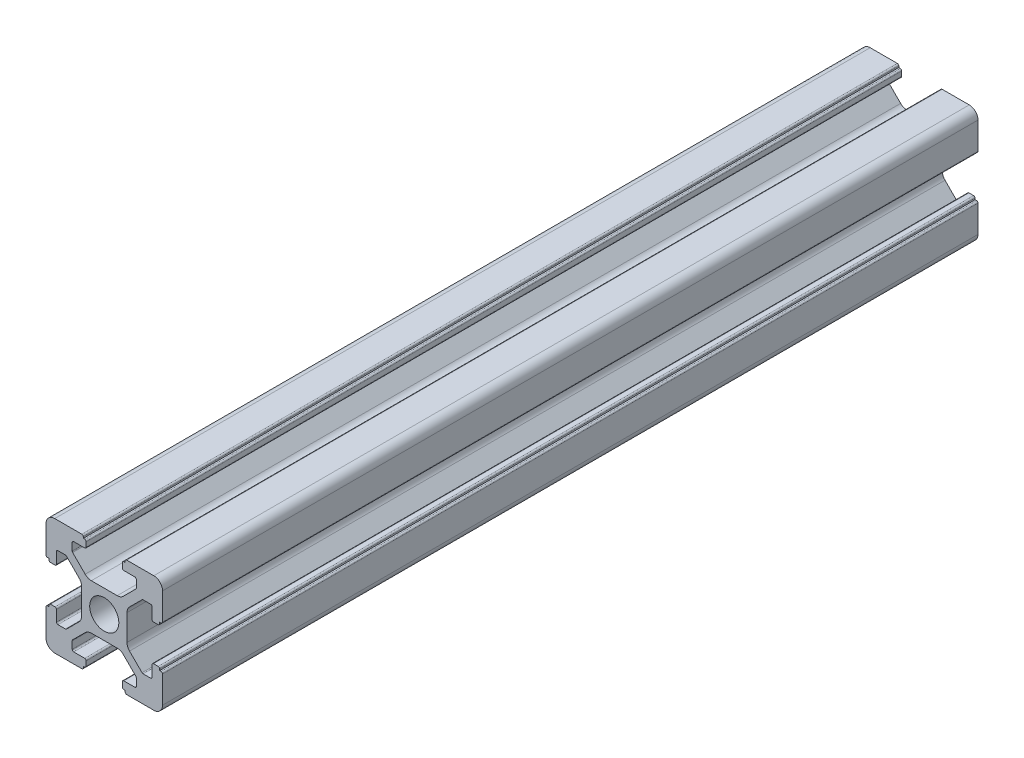
from build123d import *

# Parameters (mm, degrees)
SKETCH_1_R      = 2.5
EXTRUDE_1_DEPTH = 140


with BuildPart() as part:
    # 草图1 → 凸台-拉伸1 (new body)
    with BuildSketch(Plane.XY):
        with BuildLine():
            Line((-8.502261885, -10.002261885), (-3.85, -10.002261885))
            ThreePointArc((-3.85, -10.002261885), (-3.673223305, -9.929038581), (-3.6, -9.752261885))
            Line((-3.6, -9.752261885), (-3.6, -9.502261885))
            Line((-3.6, -9.502261885), (-3.35, -9.502261885))
            ThreePointArc((-3.35, -9.502261885), (-3.173223305, -9.429038581), (-3.1, -9.252261885))
            Line((-3.1, -9.252261885), (-3.1, -8.45))
            ThreePointArc((-3.1, -8.45), (-3.173223305, -8.273223305), (-3.35, -8.2))
            Line((-3.35, -8.2), (-5.25, -8.2))
            ThreePointArc((-5.25, -8.2), (-5.426776695, -8.126776695), (-5.5, -7.95))
            Line((-5.5, -7.95), (-5.5, -6.664213562))
            ThreePointArc((-5.5, -6.664213562), (-5.480969883, -6.568542704), (-5.426776695, -6.487436867))
            Line((-5.426776695, -6.487436867), (-3.278679656, -4.339339828))
            ThreePointArc((-3.278679656, -4.339339828), (-2.792044633, -4.014180701), (-2.218019485, -3.9))
            Line((-2.218019485, -3.9), (2.218019485, -3.9))
            ThreePointArc((2.218019485, -3.9), (2.792044633, -4.014180701), (3.278679656, -4.339339828))
            Line((3.278679656, -4.339339828), (5.426776695, -6.487436867))
            ThreePointArc((5.426776695, -6.487436867), (5.480969883, -6.568542704), (5.5, -6.664213562))
            Line((5.5, -6.664213562), (5.5, -7.95))
            ThreePointArc((5.5, -7.95), (5.426776695, -8.126776695), (5.25, -8.2))
            Line((5.25, -8.2), (3.35, -8.2))
            ThreePointArc((3.35, -8.2), (3.173223305, -8.273223305), (3.1, -8.45))
            Line((3.1, -8.45), (3.1, -9.252261885))
            ThreePointArc((3.1, -9.252261885), (3.173223305, -9.429038581), (3.35, -9.502261885))
            Line((3.35, -9.502261885), (3.6, -9.502261885))
            Line((3.6, -9.502261885), (3.6, -9.752261885))
            ThreePointArc((3.6, -9.752261885), (3.673223305, -9.929038581), (3.85, -10.002261885))
            Line((3.85, -10.002261885), (8.502261885, -10.002261885))
            ThreePointArc((8.502261885, -10.002261885), (9.562922057, -9.562922057), (10.002261885, -8.502261885))
            Line((10.002261885, -8.502261885), (10.002261885, -3.85))
            ThreePointArc((10.002261885, -3.85), (9.929038581, -3.673223305), (9.752261885, -3.6))
            Line((9.752261885, -3.6), (9.502261885, -3.6))
            Line((9.502261885, -3.6), (9.502261885, -3.35))
            ThreePointArc((9.502261885, -3.35), (9.429038581, -3.173223305), (9.252261885, -3.1))
            Line((9.252261885, -3.1), (8.45, -3.1))
            ThreePointArc((8.45, -3.1), (8.273223305, -3.173223305), (8.2, -3.35))
            Line((8.2, -3.35), (8.2, -5.25))
            ThreePointArc((8.2, -5.25), (8.126776695, -5.426776695), (7.95, -5.5))
            Line((7.95, -5.5), (6.664213562, -5.5))
            ThreePointArc((6.664213562, -5.5), (6.568542704, -5.480969883), (6.487436867, -5.426776695))
            Line((6.487436867, -5.426776695), (4.339339828, -3.278679656))
            ThreePointArc((4.339339828, -3.278679656), (4.014180701, -2.792044633), (3.9, -2.218019485))
            Line((3.9, -2.218019485), (3.9, 2.218019485))
            ThreePointArc((3.9, 2.218019485), (4.014180701, 2.792044633), (4.339339828, 3.278679656))
            Line((4.339339828, 3.278679656), (6.487436867, 5.426776695))
            ThreePointArc((6.487436867, 5.426776695), (6.568542704, 5.480969883), (6.664213562, 5.5))
            Line((6.664213562, 5.5), (7.95, 5.5))
            ThreePointArc((7.95, 5.5), (8.126776695, 5.426776695), (8.2, 5.25))
            Line((8.2, 5.25), (8.2, 3.35))
            ThreePointArc((8.2, 3.35), (8.273223305, 3.173223305), (8.45, 3.1))
            Line((8.45, 3.1), (9.252261885, 3.1))
            ThreePointArc((9.252261885, 3.1), (9.429038581, 3.173223305), (9.502261885, 3.35))
            Line((9.502261885, 3.35), (9.502261885, 3.6))
            Line((9.502261885, 3.6), (9.752261885, 3.6))
            ThreePointArc((9.752261885, 3.6), (9.929038581, 3.673223305), (10.002261885, 3.85))
            Line((10.002261885, 3.85), (10.002261885, 8.502261885))
            ThreePointArc((10.002261885, 8.502261885), (9.562922057, 9.562922057), (8.502261885, 10.002261885))
            Line((8.502261885, 10.002261885), (3.85, 10.002261885))
            ThreePointArc((3.85, 10.002261885), (3.673223305, 9.929038581), (3.6, 9.752261885))
            Line((3.6, 9.752261885), (3.6, 9.502261885))
            Line((3.6, 9.502261885), (3.35, 9.502261885))
            ThreePointArc((3.35, 9.502261885), (3.173223305, 9.429038581), (3.1, 9.252261885))
            Line((3.1, 9.252261885), (3.1, 8.45))
            ThreePointArc((3.1, 8.45), (3.173223305, 8.273223305), (3.35, 8.2))
            Line((3.35, 8.2), (5.25, 8.2))
            ThreePointArc((5.25, 8.2), (5.426776695, 8.126776695), (5.5, 7.95))
            Line((5.5, 7.95), (5.5, 6.664213562))
            ThreePointArc((5.5, 6.664213562), (5.480969883, 6.568542704), (5.426776695, 6.487436867))
            Line((5.426776695, 6.487436867), (3.278679656, 4.339339828))
            ThreePointArc((3.278679656, 4.339339828), (2.792044633, 4.014180701), (2.218019485, 3.9))
            Line((2.218019485, 3.9), (-2.218019485, 3.9))
            ThreePointArc((-2.218019485, 3.9), (-2.792044633, 4.014180701), (-3.278679656, 4.339339828))
            Line((-3.278679656, 4.339339828), (-5.426776695, 6.487436867))
            ThreePointArc((-5.426776695, 6.487436867), (-5.480969883, 6.568542704), (-5.5, 6.664213562))
            Line((-5.5, 6.664213562), (-5.5, 7.95))
            ThreePointArc((-5.5, 7.95), (-5.426776695, 8.126776695), (-5.25, 8.2))
            Line((-5.25, 8.2), (-3.35, 8.2))
            ThreePointArc((-3.35, 8.2), (-3.173223305, 8.273223305), (-3.1, 8.45))
            Line((-3.1, 8.45), (-3.1, 9.252261885))
            ThreePointArc((-3.1, 9.252261885), (-3.173223305, 9.429038581), (-3.35, 9.502261885))
            Line((-3.35, 9.502261885), (-3.6, 9.502261885))
            Line((-3.6, 9.502261885), (-3.6, 9.752261885))
            ThreePointArc((-3.6, 9.752261885), (-3.673223305, 9.929038581), (-3.85, 10.002261885))
            Line((-3.85, 10.002261885), (-8.502261885, 10.002261885))
            ThreePointArc((-8.502261885, 10.002261885), (-9.562922057, 9.562922057), (-10.002261885, 8.502261885))
            Line((-10.002261885, 8.502261885), (-10.002261885, 3.85))
            ThreePointArc((-10.002261885, 3.85), (-9.929038581, 3.673223305), (-9.752261885, 3.6))
            Line((-9.752261885, 3.6), (-9.502261885, 3.6))
            Line((-9.502261885, 3.6), (-9.502261885, 3.35))
            ThreePointArc((-9.502261885, 3.35), (-9.429038581, 3.173223305), (-9.252261885, 3.1))
            Line((-9.252261885, 3.1), (-8.45, 3.1))
            ThreePointArc((-8.45, 3.1), (-8.273223305, 3.173223305), (-8.2, 3.35))
            Line((-8.2, 3.35), (-8.2, 5.25))
            ThreePointArc((-8.2, 5.25), (-8.126776695, 5.426776695), (-7.95, 5.5))
            Line((-7.95, 5.5), (-6.664213562, 5.5))
            ThreePointArc((-6.664213562, 5.5), (-6.568542704, 5.480969883), (-6.487436867, 5.426776695))
            Line((-6.487436867, 5.426776695), (-4.339339828, 3.278679656))
            ThreePointArc((-4.339339828, 3.278679656), (-4.014180701, 2.792044633), (-3.9, 2.218019485))
            Line((-3.9, 2.218019485), (-3.9, -2.218019485))
            ThreePointArc((-3.9, -2.218019485), (-4.014180701, -2.792044633), (-4.339339828, -3.278679656))
            Line((-4.339339828, -3.278679656), (-6.487436867, -5.426776695))
            ThreePointArc((-6.487436867, -5.426776695), (-6.568542704, -5.480969883), (-6.664213562, -5.5))
            Line((-6.664213562, -5.5), (-7.95, -5.5))
            ThreePointArc((-7.95, -5.5), (-8.126776695, -5.426776695), (-8.2, -5.25))
            Line((-8.2, -5.25), (-8.2, -3.35))
            ThreePointArc((-8.2, -3.35), (-8.273223305, -3.173223305), (-8.45, -3.1))
            Line((-8.45, -3.1), (-9.252261885, -3.1))
            ThreePointArc((-9.252261885, -3.1), (-9.429038581, -3.173223305), (-9.502261885, -3.35))
            Line((-9.502261885, -3.35), (-9.502261885, -3.6))
            Line((-9.502261885, -3.6), (-9.752261885, -3.6))
            ThreePointArc((-9.752261885, -3.6), (-9.929038581, -3.673223305), (-10.002261885, -3.85))
            Line((-10.002261885, -3.85), (-10.002261885, -8.502261885))
            ThreePointArc((-10.002261885, -8.502261885), (-9.562922057, -9.562922057), (-8.502261885, -10.002261885))
        make_face()
        Circle(SKETCH_1_R, mode=Mode.SUBTRACT)
    extrude(amount=EXTRUDE_1_DEPTH)


solid = part.part
